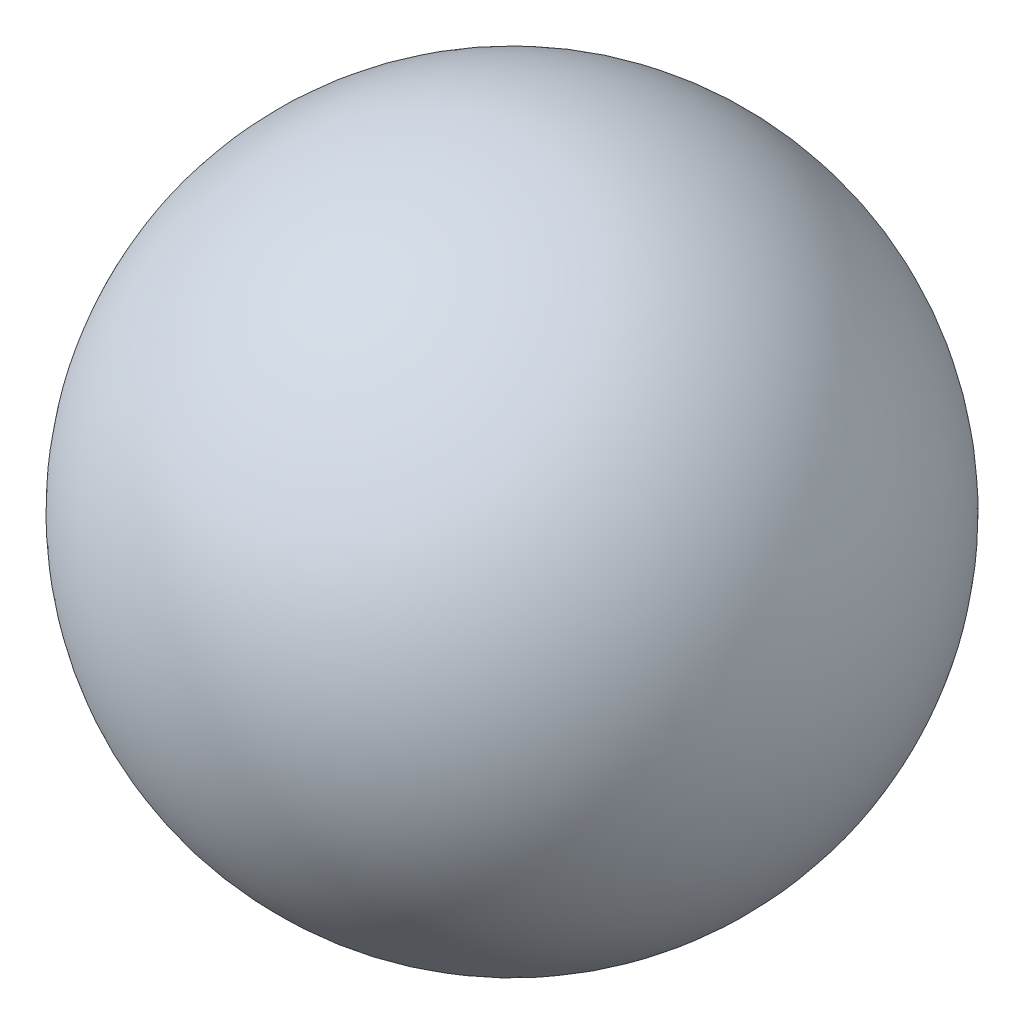
from build123d import *


with BuildPart() as part:
    # Sketch1 → Revolve1 (revolve)
    with BuildSketch(Plane(origin=(0, 0, 0), x_dir=(1, 0, 0), z_dir=(0, 1, 0))):
        with BuildLine():
            Line((-63.5, 0), (63.5, 0))
            ThreePointArc((63.5, 0), (0, 63.5), (-63.5, 0))
        make_face()
    revolve(axis=Axis((-63.5, 0, 0), (1, 0, 0)))


solid = part.part
